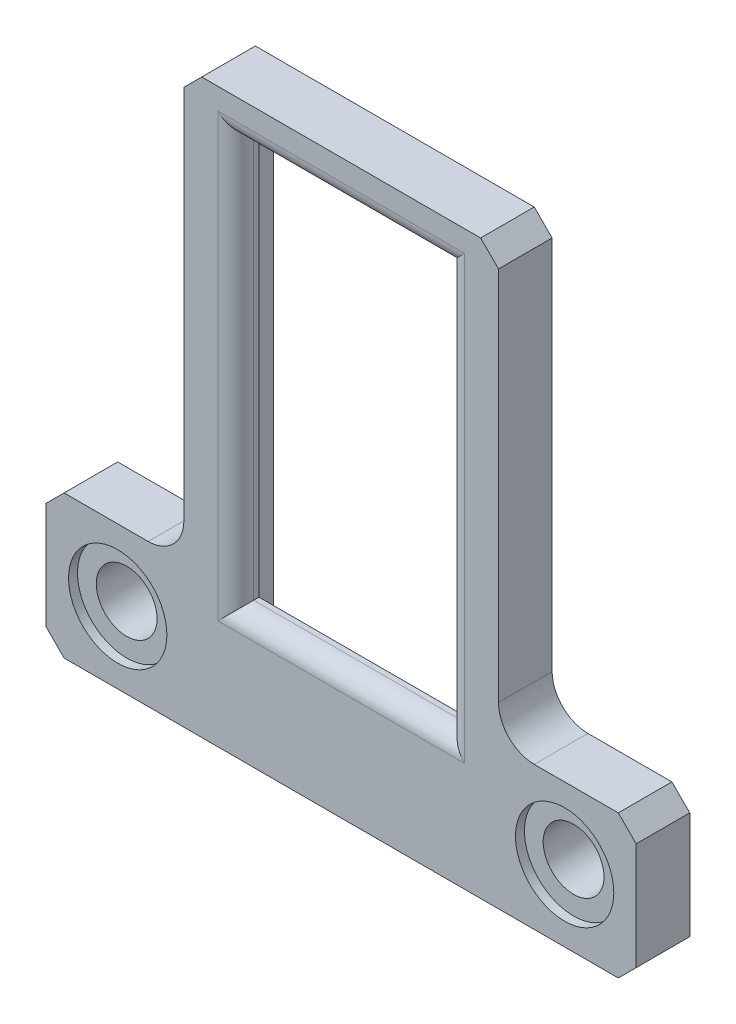
from build123d import *

# Parameters (mm, degrees)
EXTRUDE_1_DEPTH              = 3
SKETCH_2_W                   = 13.6
SKETCH_2_H                   = 29
CUT_EXTRUDE_1_DEPTH          = 1.7
SKETCH_3_W                   = 11.8
SKETCH_3_H                   = 22.7
CUT_EXTRUDE_2_DEPTH          = 4
HOLE_WIZARD_M3_1_D           = 3.4
HOLE_WIZARD_M3_1_DEPTH       = 7.5
HOLE_WIZARD_M3_1_CBORE_D     = 5.5
HOLE_WIZARD_M3_1_CBORE_DEPTH = 0.5
HOLE_WIZARD_M3_1_TIP         = 1.021463052
CHAMFER_1_SIZE               = 1
FILLET_1_R                   = 2
FILLET_3_R                   = 1


with BuildPart() as part:
    # 草图1 → 凸台-拉伸1 (new body)
    with BuildSketch(Plane.XY):
        Polygon((-7.7, -32), (25.3, -32), (25.3, -24), (17.6, -24), (17.6, 0), (0, 0), (0, -24), (-7.7, -24), align=None)
    extrude(amount=EXTRUDE_1_DEPTH)

    # 草图2 → 切除-拉伸1 (cut)
    with BuildSketch(Plane(origin=(0, 0, 0), x_dir=(-1, 0, 0), z_dir=(0, 0, -1))):
        with Locations((-8.8, -15.5)):
            Rectangle(SKETCH_2_W, SKETCH_2_H)
    extrude(amount=-CUT_EXTRUDE_1_DEPTH, mode=Mode.SUBTRACT)

    # 草图3 → 切除-拉伸2 (cut, through all)
    with BuildSketch(Plane.XY.offset(3)):
        with Locations((8.8, -13.55)):
            Rectangle(SKETCH_3_W, SKETCH_3_H)
    extrude(amount=-CUT_EXTRUDE_2_DEPTH, mode=Mode.SUBTRACT)

    # M3 六角头螺栓的柱形沉头孔1
    with Locations(Plane.XY.offset(3)):
        with Locations((-3.7, -28), (21.3, -28)):
            CounterBoreHole(HOLE_WIZARD_M3_1_D / 2, HOLE_WIZARD_M3_1_CBORE_D / 2, HOLE_WIZARD_M3_1_CBORE_DEPTH, depth=HOLE_WIZARD_M3_1_DEPTH)
            with Locations((0, 0, -(HOLE_WIZARD_M3_1_DEPTH + HOLE_WIZARD_M3_1_TIP / 2))):  # 118° drill point
                Cone(0, HOLE_WIZARD_M3_1_D / 2, HOLE_WIZARD_M3_1_TIP, mode=Mode.SUBTRACT)

    # 倒角1
    chamfer_1_edges = [part.edges().sort_by_distance(p)[0] for p in [
        (0, 0, 1.5),
        (17.6, 0, 1.5),
        (25.3, -24, 1.5),
        (25.3, -32, 1.5),
        (-7.7, -32, 1.5),
        (-7.7, -24, 1.5),
    ]]
    chamfer(chamfer_1_edges, length=CHAMFER_1_SIZE)

    # 圆角1
    fillet_1_edges = [part.edges().sort_by_distance(p)[0] for p in [
        (17.6, -24, 1.5),
        (0, -24, 1.5),
    ]]
    fillet(fillet_1_edges, radius=FILLET_1_R)

    # 圆角3
    fillet_3_edges = [part.edges().sort_by_distance(p)[0] for p in [
        (2.9, -13.55, 3),
        (8.8, -24.9, 3),
        (14.7, -13.55, 3),
        (8.8, -2.2, 3),
    ]]
    fillet(fillet_3_edges, radius=FILLET_3_R)


solid = part.part
